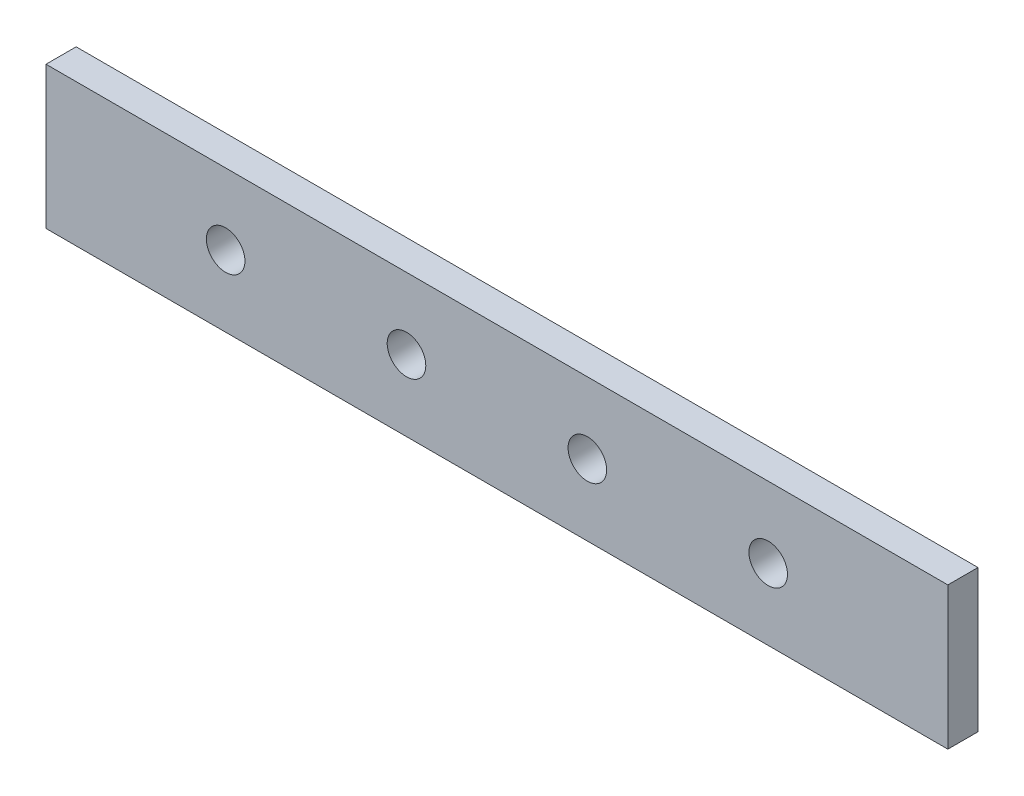
from build123d import *

# Parameters (mm, degrees)
CROQUIS1_W              = 74.8
CROQUIS1_H              = 11.8
SALIENTE_EXTRUIR1_DEPTH = 2.5
CORTAR_EXTRUIR1_REACH   = 4.5
CROQUIS2_R              = 1.6


with BuildPart() as part:
    # Croquis1 → Saliente-Extruir1 (new body)
    with BuildSketch(Plane.XY):
        with Locations((0, -76)):
            Rectangle(CROQUIS1_W, CROQUIS1_H)
    extrude(amount=SALIENTE_EXTRUIR1_DEPTH)

    # Croquis2 → Cortar-Extruir1 (cut, up to next)
    with BuildSketch(Plane.XY.offset(2.5), mode=Mode.PRIVATE) as cortar_extruir1_sk1:
        with Locations((-22.5, -76)):
            Circle(CROQUIS2_R)
    cortar_extruir1_tool1 = extrude(cortar_extruir1_sk1.sketch, amount=-CORTAR_EXTRUIR1_REACH, mode=Mode.PRIVATE) & part.part
    add(cortar_extruir1_tool1.solids().sort_by_distance((-22.5, -76, 2.5))[0], mode=Mode.SUBTRACT)
    # Croquis2 → Cortar-Extruir1 (cut, up to next)
    with BuildSketch(Plane.XY.offset(2.5), mode=Mode.PRIVATE) as cortar_extruir1_sk2:
        with Locations((22.5, -76)):
            Circle(CROQUIS2_R)
    cortar_extruir1_tool2 = extrude(cortar_extruir1_sk2.sketch, amount=-CORTAR_EXTRUIR1_REACH, mode=Mode.PRIVATE) & part.part
    add(cortar_extruir1_tool2.solids().sort_by_distance((22.5, -76, 2.5))[0], mode=Mode.SUBTRACT)
    # Croquis2 → Cortar-Extruir1 (cut, up to next)
    with BuildSketch(Plane.XY.offset(2.5), mode=Mode.PRIVATE) as cortar_extruir1_sk3:
        with Locations((-7.5, -76)):
            Circle(CROQUIS2_R)
    cortar_extruir1_tool3 = extrude(cortar_extruir1_sk3.sketch, amount=-CORTAR_EXTRUIR1_REACH, mode=Mode.PRIVATE) & part.part
    add(cortar_extruir1_tool3.solids().sort_by_distance((-7.5, -76, 2.5))[0], mode=Mode.SUBTRACT)
    # Croquis2 → Cortar-Extruir1 (cut, up to next)
    with BuildSketch(Plane.XY.offset(2.5), mode=Mode.PRIVATE) as cortar_extruir1_sk4:
        with Locations((7.5, -76)):
            Circle(CROQUIS2_R)
    cortar_extruir1_tool4 = extrude(cortar_extruir1_sk4.sketch, amount=-CORTAR_EXTRUIR1_REACH, mode=Mode.PRIVATE) & part.part
    add(cortar_extruir1_tool4.solids().sort_by_distance((7.5, -76, 2.5))[0], mode=Mode.SUBTRACT)


solid = part.part
